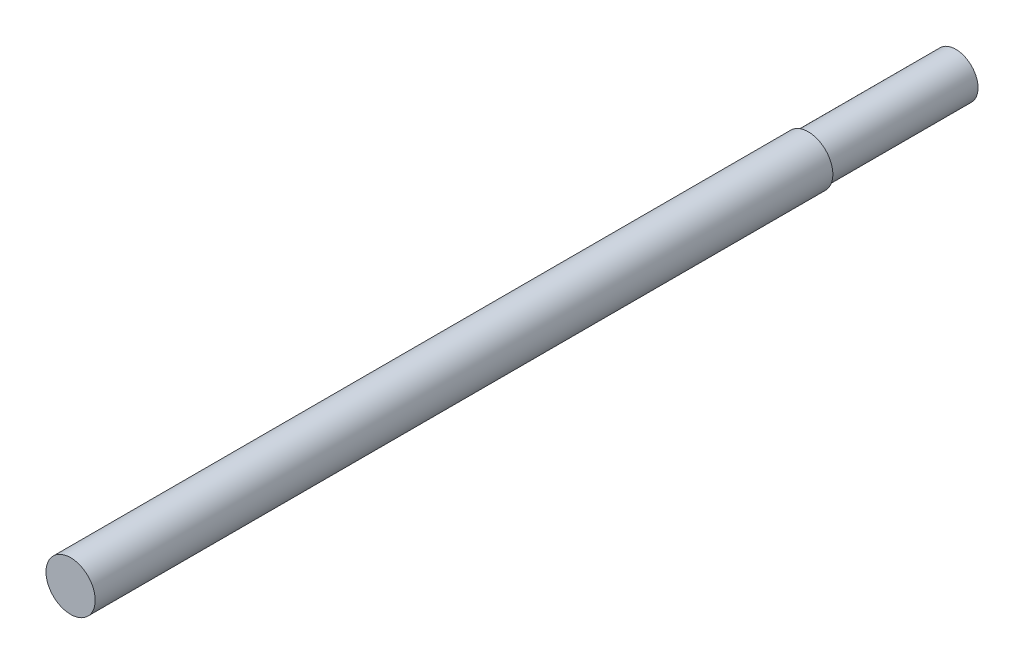
from build123d import *

# Parameters (mm, degrees)
SKETCH3_R                = 25.4
BOSS_EXTRUDE1_DEPTH      = 457.2
BOSS_EXTRUDE1_DEPTH_BACK = 457.2
SKETCH4_R                = 9.525
CUT_EXTRUDE2_DEPTH       = 19.05
SKETCH5_R                = 25.4
SKETCH5_R_2              = 23
CUT_EXTRUDE3_DEPTH       = 152.4


with BuildPart() as part:
    # Sketch3 → Boss-Extrude1 (new body, two sides)
    with BuildSketch(Plane.XY) as boss_extrude1_sk:
        Circle(SKETCH3_R)
    extrude(amount=BOSS_EXTRUDE1_DEPTH)
    extrude(boss_extrude1_sk.sketch, amount=-BOSS_EXTRUDE1_DEPTH_BACK)

    # Sketch4 → Cut-Extrude2 (cut)
    with BuildSketch(Plane.XY.offset(-457.2)):
        Circle(SKETCH4_R)
    extrude(amount=CUT_EXTRUDE2_DEPTH, mode=Mode.SUBTRACT)

    # Sketch5 → Cut-Extrude3 (cut)
    with BuildSketch(Plane(origin=(0, 0, -457.2), x_dir=(-1, 0, 0), z_dir=(0, 0, -1))):
        Circle(SKETCH5_R)
        Circle(SKETCH5_R_2, mode=Mode.SUBTRACT)
    extrude(amount=-CUT_EXTRUDE3_DEPTH, mode=Mode.SUBTRACT)


solid = part.part
